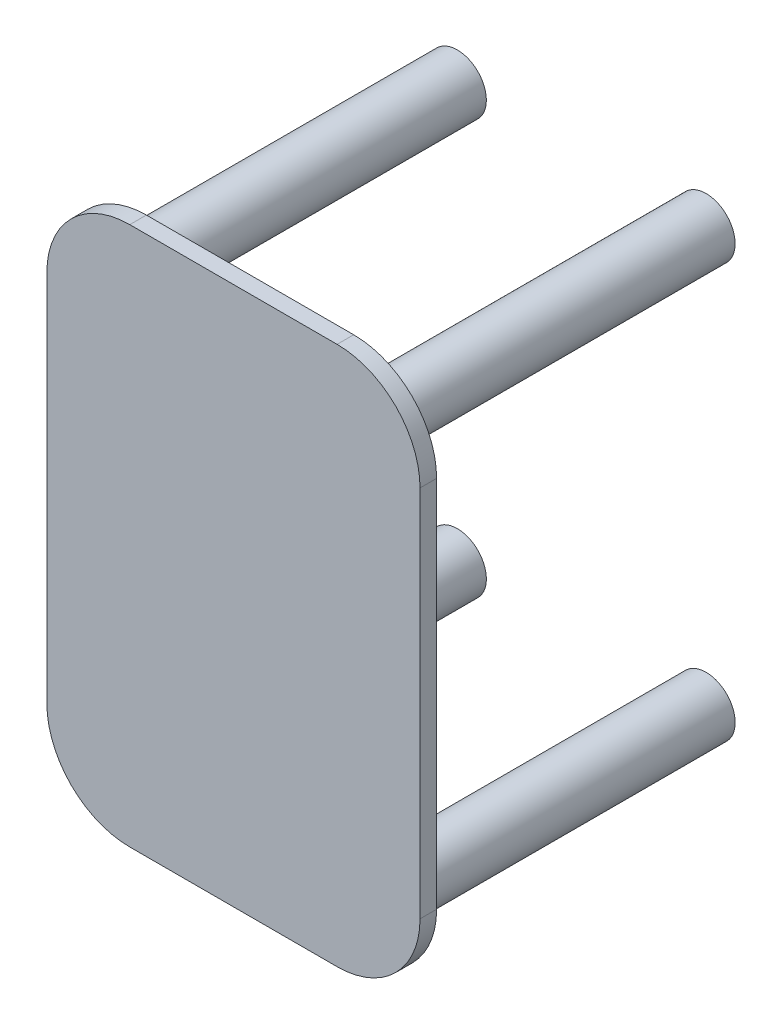
from build123d import *

# Parameters (mm, degrees)
SKETCH1_R             = 0.035
BOSS_EXTRUDE1_DEPTH   = 0.4
BOSS_EXTRUDE1_2_DEPTH = 0.4
BOSS_EXTRUDE1_3_DEPTH = 0.4
BOSS_EXTRUDE1_4_DEPTH = 0.4
BOSS_EXTRUDE2_DEPTH   = 0.02


with BuildPart() as part:
    # Sketch1 → Boss-Extrude1 (new body)
    with BuildSketch(Plane.XY):
        with Locations((-0.15, 0.25)):
            Circle(SKETCH1_R)
    extrude(amount=BOSS_EXTRUDE1_DEPTH)


with BuildPart() as body_2:
    # Sketch1 → Boss-Extrude1 2 (new body)
    with BuildSketch(Plane.XY):
        with Locations((-0.15, -0.25)):
            Circle(SKETCH1_R)
    extrude(amount=BOSS_EXTRUDE1_2_DEPTH)


with BuildPart() as body_3:
    # Sketch1 → Boss-Extrude1 3 (new body)
    with BuildSketch(Plane.XY):
        with Locations((0.15, -0.25)):
            Circle(SKETCH1_R)
    extrude(amount=BOSS_EXTRUDE1_3_DEPTH)


with BuildPart() as body_4:
    # Sketch1 → Boss-Extrude1 4 (new body)
    with BuildSketch(Plane.XY):
        with Locations((0.15, 0.25)):
            Circle(SKETCH1_R)
    extrude(amount=BOSS_EXTRUDE1_4_DEPTH)


with BuildPart() as body_5:
    # Sketch2 → Boss-Extrude2 (new body)
    with BuildSketch(Plane.XY.offset(0.4)):
        with BuildLine():
            Line((-0.125, -0.325), (0.125, -0.325))
            ThreePointArc((0.125, -0.325), (0.195710678, -0.295710678), (0.225, -0.225))
            Line((0.225, -0.225), (0.225, 0.225))
            ThreePointArc((0.225, 0.225), (0.195710678, 0.295710678), (0.125, 0.325))
            Line((0.125, 0.325), (-0.125, 0.325))
            ThreePointArc((-0.125, 0.325), (-0.195710678, 0.295710678), (-0.225, 0.225))
            Line((-0.225, 0.225), (-0.225, -0.225))
            ThreePointArc((-0.225, -0.225), (-0.195710678, -0.295710678), (-0.125, -0.325))
        make_face()
    extrude(amount=BOSS_EXTRUDE2_DEPTH)


solid = Compound([part.part, body_2.part, body_3.part, body_4.part, body_5.part])
